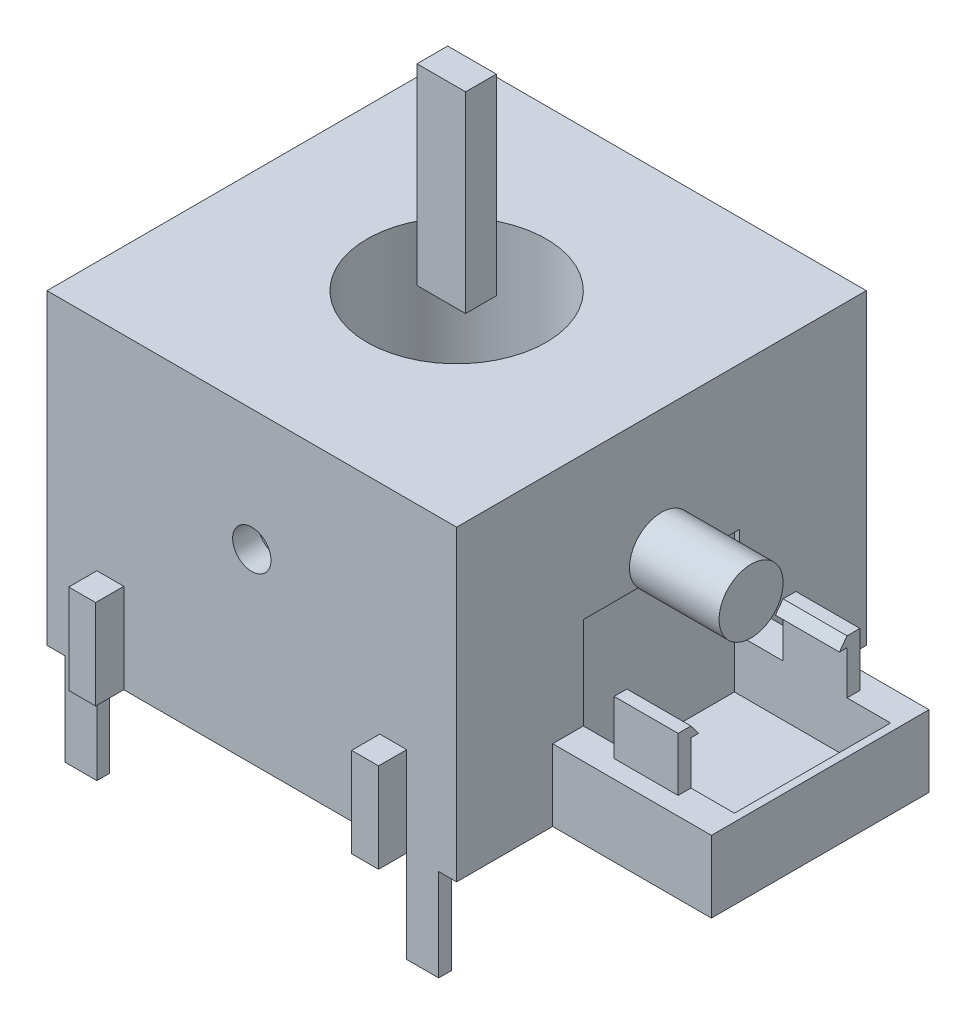
from build123d import *

# Parameters (mm, degrees)
ESQUISSE1_W                  = 16
ESQUISSE1_H                  = 16
ESQUISSE1_R                  = 3.5
BOSS_EXTRU_1_DEPTH           = 12
ESQUISSE2_W                  = 1.25
ESQUISSE2_H                  = 0.5
BOSS_EXTRU_2_DEPTH           = 3.6
ESQUISSE5_R                  = 0.75
ENL_V_MAT_EXTRU_2_DEPTH      = 1
ESQUISSE6_W                  = 6.2
ESQUISSE6_H                  = 8.5
BOSS_EXTRU_4_DEPTH           = 2.8
ESQUISSE7_W                  = 6.1
ESQUISSE7_H                  = 6.1
ENL_V_MAT_EXTRU_3_DEPTH      = 3.6
ENL_V_MAT_EXTRU_3_DEPTH_BACK = 2
ESQUISSE3_R                  = 1.25
BOSS_EXTRU_3_DEPTH           = 3.5
BOSS_EXTRU_5_START           = -2
BOSS_EXTRU_5_DEPTH           = 2.5
ESQUISSE10_W                 = 1.05
ESQUISSE10_H                 = 3.5
BOSS_EXTRU_6_DEPTH           = 1.1
ESQUISSE11_W                 = 1.9
ESQUISSE11_H                 = 1.2
BOSS_EXTRU_7_DEPTH           = 7.5


with BuildPart() as part:
    # Esquisse1 → Boss.-Extru.1 (new body)
    with BuildSketch(Plane(origin=(0, 0, 0), x_dir=(1, 0, 0), z_dir=(0, 1, 0))):
        Rectangle(ESQUISSE1_W, ESQUISSE1_H)
        with Locations(Location((0, 0, 0), (0, 0, 270))):  # turned: the seam where the file's is
            Circle(ESQUISSE1_R, mode=Mode.SUBTRACT)
    extrude(amount=BOSS_EXTRU_1_DEPTH)

    # Esquisse2 → Boss.-Extru.2 (add)
    with BuildSketch(Plane.XZ):
        with Locations((-6.675, 7.75)):
            Rectangle(ESQUISSE2_W, ESQUISSE2_H)
        with Locations((6.675, 7.75)):
            Rectangle(ESQUISSE2_W, ESQUISSE2_H)
        with Locations((6.675, -7.75)):
            Rectangle(ESQUISSE2_W, ESQUISSE2_H)
        with Locations((-6.675, -7.75)):
            Rectangle(ESQUISSE2_W, ESQUISSE2_H)
    extrude(amount=BOSS_EXTRU_2_DEPTH)

    # Esquisse5 → Enlèv. mat.-Extru.2 (cut)
    with BuildSketch(Plane.XY.offset(8)):
        with Locations((0, 7.25)):
            Circle(ESQUISSE5_R)
    extrude(amount=-ENL_V_MAT_EXTRU_2_DEPTH, mode=Mode.SUBTRACT)

    # Esquisse6 → Boss.-Extru.4 (add)
    with BuildSketch(Plane.XZ):
        with Locations((11.1, 0)):
            Rectangle(ESQUISSE6_W, ESQUISSE6_H)
    extrude(amount=-BOSS_EXTRU_4_DEPTH)

    # Esquisse7 → Enlèv. mat.-Extru.3 (cut, two sides)
    with BuildSketch(Plane(origin=(0, 2.8, 0), x_dir=(1, 0, 0), z_dir=(0, 1, 0))) as enl_v_mat_extru_3_sk:
        with Locations((10.85, 0)):
            Rectangle(ESQUISSE7_W, ESQUISSE7_H)
    extrude(amount=ENL_V_MAT_EXTRU_3_DEPTH, mode=Mode.SUBTRACT)
    extrude(enl_v_mat_extru_3_sk.sketch, amount=-ENL_V_MAT_EXTRU_3_DEPTH_BACK, mode=Mode.SUBTRACT)

    # Esquisse3 → Boss.-Extru.3 (add)
    with BuildSketch(Plane.ZY.offset(-8)):
        with Locations((0, 7.25)):
            Circle(ESQUISSE3_R)
    extrude(amount=-BOSS_EXTRU_3_DEPTH)

    # Esquisse9 → Boss.-Extru.5 (add)
    with BuildSketch(Plane(origin=(14.2, 0, 0), x_dir=(0, 0, -1), z_dir=(1, 0, 0)).offset(BOSS_EXTRU_5_START)):
        Polygon((-3.05, 2.8), (-3.05, 4.5), (-2.75, 4.5), (-3.05, 4.9), (-3.55, 4.9), (-3.55, 2.8), align=None)
    boss_extru_5 = extrude(amount=-BOSS_EXTRU_5_DEPTH)

    # Symétrie1: Boss.-Extru.5 across plane
    add(boss_extru_5.mirror(Plane.XY))

    # Esquisse10 → Boss.-Extru.6 (add)
    with BuildSketch(Plane.XY.offset(8)):
        with Locations((-5.525, 1.75)):
            Rectangle(ESQUISSE10_W, ESQUISSE10_H)
        with Locations((5.525, 1.75)):
            Rectangle(ESQUISSE10_W, ESQUISSE10_H)
    extrude(amount=BOSS_EXTRU_6_DEPTH)


with BuildPart() as body_2:
    # Esquisse11 → Boss.-Extru.7 (new body)
    with BuildSketch(Plane(origin=(0, 12, 0), x_dir=(1, 0, 0), z_dir=(0, 1, 0))):
        Rectangle(ESQUISSE11_W, ESQUISSE11_H)
    extrude(amount=BOSS_EXTRU_7_DEPTH)


solid = Compound([part.part, body_2.part])
